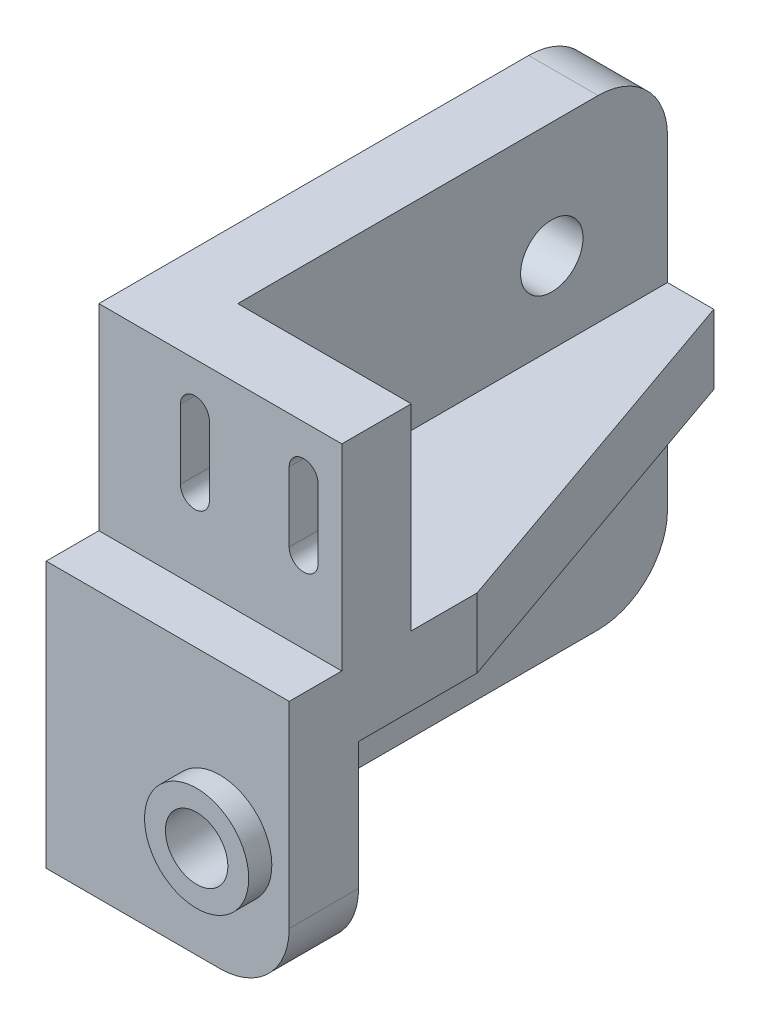
from build123d import *

# Parameters (mm, degrees)
SKETCH1_W             = 43.15
SKETCH1_H             = 40
BOSS_EXTRUDE1_DEPTH   = 6
BOSS_EXTRUDE2_DEPTH   = 21
CHAMFER1_SIZE         = 11
CHAMFER1_SIZE2        = 31.45
F_5_4MM_DOWEL_HOLE1_D = 5.4
SKETCH8_R             = 4.5
BOSS_EXTRUDE3_DEPTH   = 2
F_5_4MM_DOWEL_HOLE2_D = 5.4
CUT_EXTRUDE1_DEPTH    = 44.15
FILLET1_R             = 6
FILLET2_R             = 6


with BuildPart() as part:
    # Sketch1 → Boss-Extrude1 (new body)
    with BuildSketch(Plane(origin=(0, 0, 0), x_dir=(0, 0, -1), z_dir=(1, 0, 0))):
        with Locations((21.575, 20)):
            Rectangle(SKETCH1_W, SKETCH1_H)
    extrude(amount=BOSS_EXTRUDE1_DEPTH)

    # Sketch2 → Boss-Extrude2 (add)
    with BuildSketch(Plane(origin=(0, 0, 0), x_dir=(0, 0, -1), z_dir=(1, 0, 0))):
        Polygon((-4.55, 23), (0, 23), (0, 40), (6, 40), (6, 23), (43.15, 23), (43.15, 17), (1.45, 17), (1.45, 0), (-4.55, 0), align=None)
    extrude(amount=BOSS_EXTRUDE2_DEPTH)

    # Chamfer1
    chamfer1_edges = [part.edges().sort_by_distance(p)[0] for p in [
        (21, 20, -43.15),
    ]]
    chamfer1_side = [part.faces().sort_by_distance(p)[0] for p in [
        (5.863636364, 20, -43.15),
    ]]
    chamfer(chamfer1_edges, length=CHAMFER1_SIZE, length2=CHAMFER1_SIZE2, reference=chamfer1_side[0])

    # Ø5.4mm Dowel Hole1 (through all)
    with Locations(Plane.ZY):
        with Locations((-33.15, 30), (-33.15, 10)):
            Hole(F_5_4MM_DOWEL_HOLE1_D / 2)

    # Sketch8 → Boss-Extrude3 (add)
    with BuildSketch(Plane.XY.offset(4.55)):
        with Locations((15, 10)):
            Circle(SKETCH8_R)
    extrude(amount=BOSS_EXTRUDE3_DEPTH)

    # Ø5.4mm Dowel Hole2 (through all)
    with Locations(Plane.XY.offset(6.55)):
        with Locations((15, 10)):
            Hole(F_5_4MM_DOWEL_HOLE2_D / 2)

    # Sketch11 → Cut-Extrude1 (cut, through all)
    with BuildSketch(Plane.XY):
        with BuildLine():
            Line((18.95, 36), (18.95, 30))
            ThreePointArc((18.95, 30), (17.7, 28.75), (16.45, 30))
            Line((16.45, 30), (16.45, 36))
            ThreePointArc((16.45, 36), (17.7, 37.25), (18.95, 36))
        make_face()
        with BuildLine():
            Line((9.55, 36), (9.55, 30))
            ThreePointArc((9.55, 30), (8.3, 28.75), (7.05, 30))
            Line((7.05, 30), (7.05, 36))
            ThreePointArc((7.05, 36), (8.3, 37.25), (9.55, 36))
        make_face()
    extrude(amount=-CUT_EXTRUDE1_DEPTH, mode=Mode.SUBTRACT)

    # Fillet1
    fillet1_edges = [part.edges().sort_by_distance(p)[0] for p in [
        (21, 0, 1.55),
    ]]
    fillet(fillet1_edges, radius=FILLET1_R)

    # Fillet2
    fillet2_edges = [part.edges().sort_by_distance(p)[0] for p in [
        (3, 0, -43.15),
        (3, 40, -43.15),
    ]]
    fillet(fillet2_edges, radius=FILLET2_R)


solid = part.part
